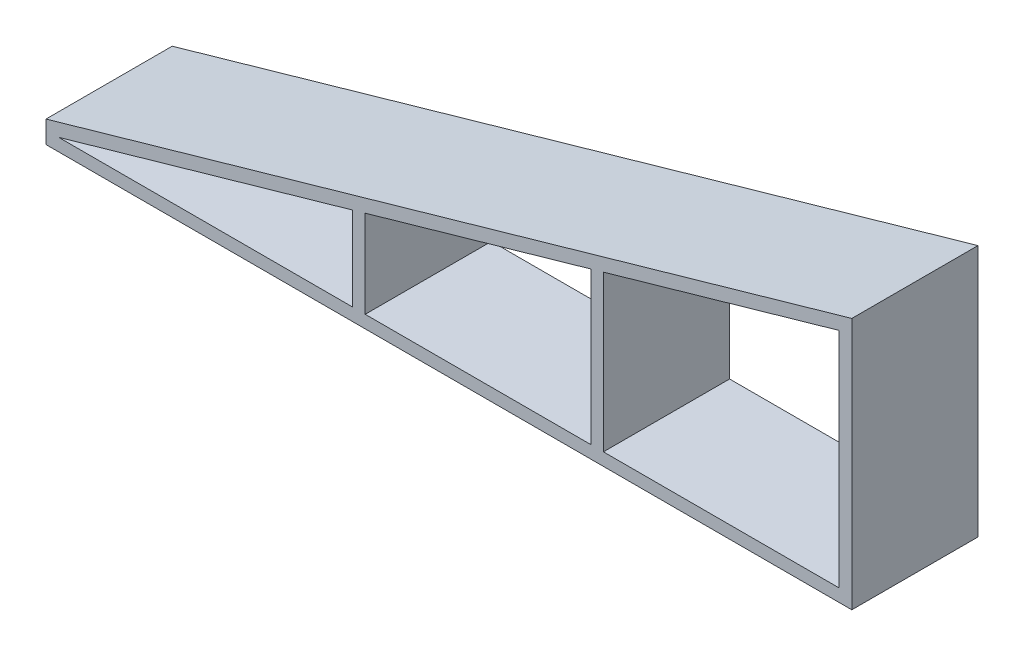
from build123d import *

# Parameters (mm, degrees)
BOSS_EXTRUDE1_DEPTH = 10


with BuildPart() as part:
    # Sketch1 → Boss-Extrude1 (new body)
    with BuildSketch(Plane.XY):
        Polygon((28.479998469, 5.585850997), (28.479998469, -14.414149003), (-35.379946586, -14.414149003), (-35.379946586, -12.65984759), align=None)
        Polygon((27.479998469, 4.260121013), (27.479998469, -13.414149003), (8.794915094, -13.414149003), (8.794915094, -1.078474237), align=None, mode=Mode.SUBTRACT)
        Polygon((7.794915094, -1.364188523), (7.794915094, -13.414149003), (-10.083352731, -13.414149003), (-10.083352731, -6.472265045), align=None, mode=Mode.SUBTRACT)
        Polygon((-11.083352731, -6.75797933), (-11.083352731, -13.414149003), (-34.379946586, -13.414149003), align=None, mode=Mode.SUBTRACT)
    extrude(amount=BOSS_EXTRUDE1_DEPTH)


solid = part.part
